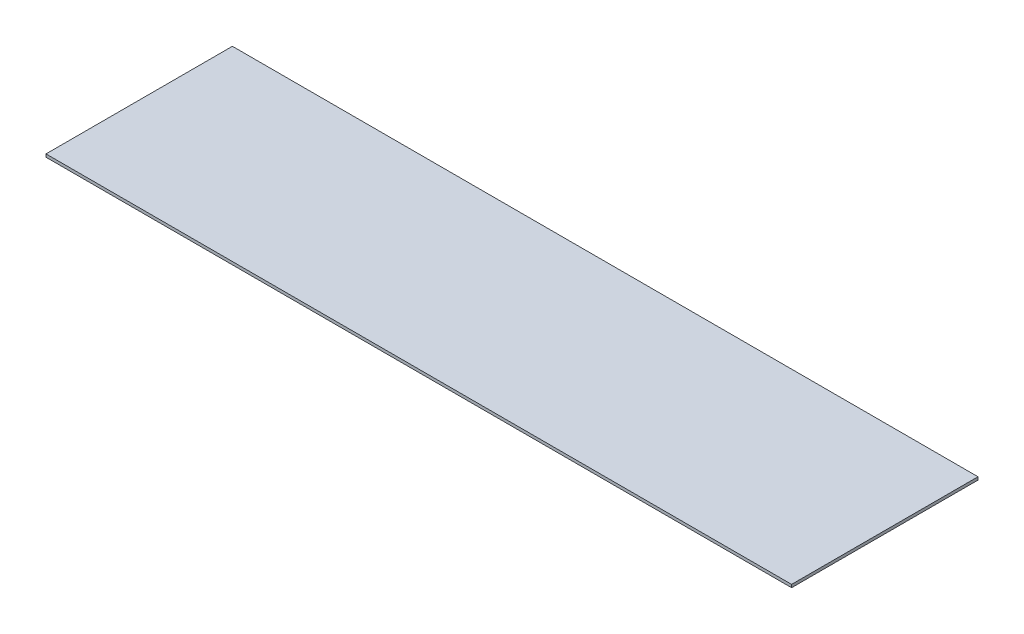
from build123d import *

# Parameters (mm, degrees)
SKETCH1_W           = 406.4
SKETCH1_H           = 101.6
BOSS_EXTRUDE1_DEPTH = 1.5875


with BuildPart() as part:
    # Sketch1 → Boss-Extrude1 (new body)
    with BuildSketch(Plane.XZ.offset(80.26236602)):
        with Locations((203.2, 50.8)):
            Rectangle(SKETCH1_W, SKETCH1_H)
    extrude(amount=BOSS_EXTRUDE1_DEPTH)


solid = part.part
